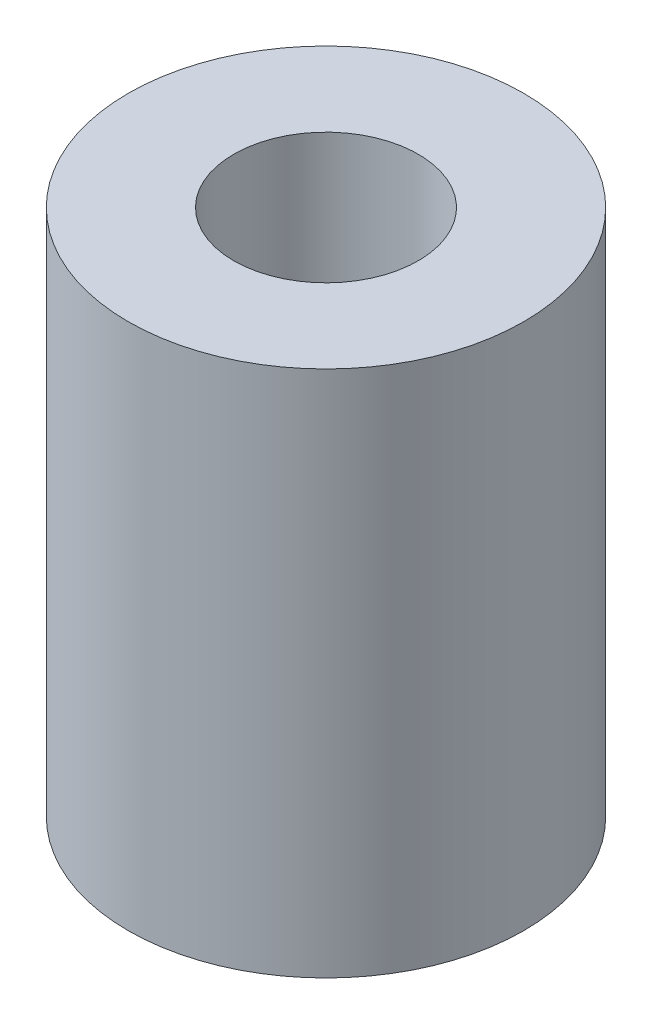
from build123d import *

# Parameters (mm, degrees)
SKETCH1_R           = 3.75
SKETCH1_R_2         = 1.75
BOSS_EXTRUDE1_DEPTH = 10


with BuildPart() as part:
    # Sketch1 → Boss-Extrude1 (new body)
    with BuildSketch(Plane(origin=(0, 0, 0), x_dir=(1, 0, 0), z_dir=(0, 1, 0))):
        Circle(SKETCH1_R)
        Circle(SKETCH1_R_2, mode=Mode.SUBTRACT)
    extrude(amount=BOSS_EXTRUDE1_DEPTH)


solid = part.part
